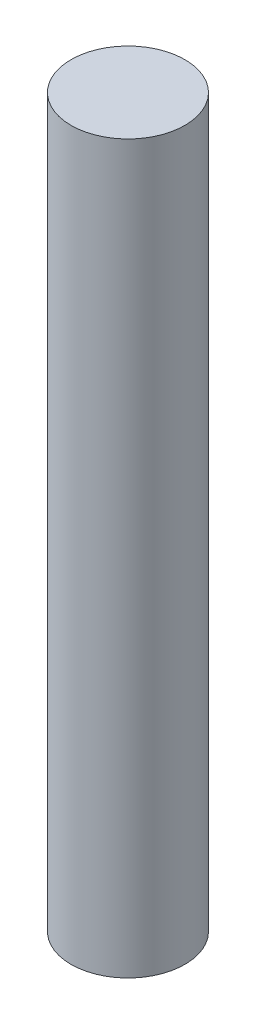
from build123d import *

# Parameters (mm, degrees)
SKETCH1_R           = 14.5
BOSS_EXTRUDE1_DEPTH = 185


with BuildPart() as part:
    # Sketch1 → Boss-Extrude1 (new body)
    with BuildSketch(Plane(origin=(0, 0, 0), x_dir=(1, 0, 0), z_dir=(0, 1, 0))):
        Circle(SKETCH1_R)
    extrude(amount=BOSS_EXTRUDE1_DEPTH)


solid = part.part
